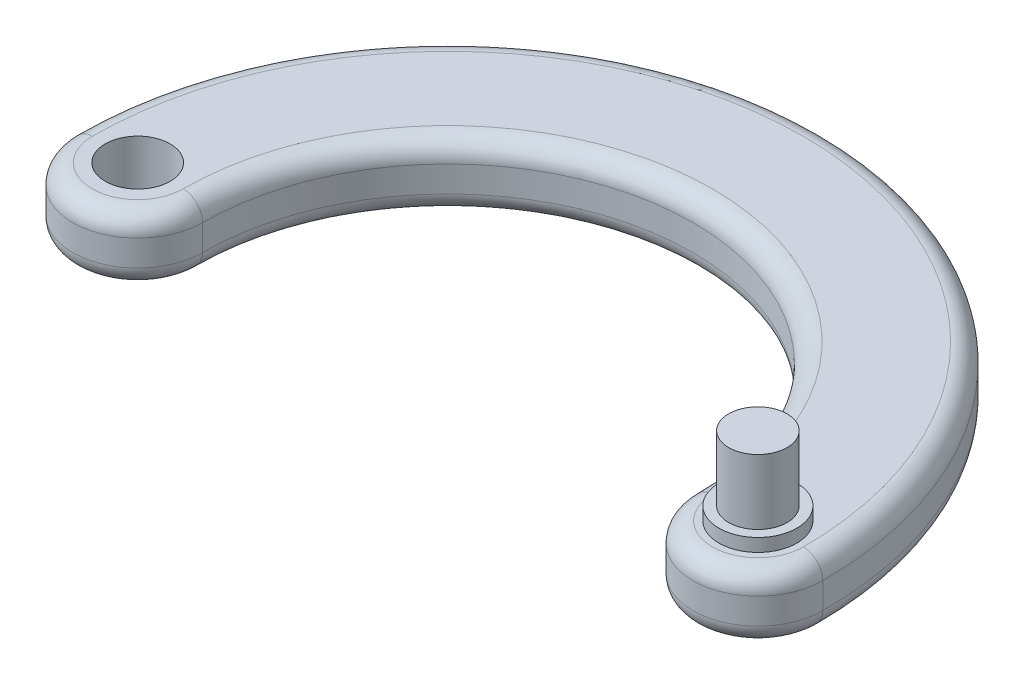
from build123d import *

# Parameters (mm, degrees)
SKETCH1_R                = 5
BOSS_EXTRUDE1_DEPTH      = 10
SKETCH2_R                = 4.5
BOSS_EXTRUDE2_DEPTH      = 12
BOSS_EXTRUDE2_DEPTH_BACK = 10
SKETCH3_R                = 5
BOSS_EXTRUDE3_DEPTH      = 10
SKETCH4_R                = 6
BOSS_EXTRUDE4_DEPTH      = 2
FILLET1_R                = 3


with BuildPart() as part:
    # Sketch1 → Boss-Extrude1 (new body)
    with BuildSketch(Plane(origin=(0, 0, 0), x_dir=(1, 0, 0), z_dir=(0, 1, 0))):
        with BuildLine():
            ThreePointArc((-10, 0), (0, -10), (10, 0))
            ThreePointArc((10, 0), (-47.75, 57.75), (-105.5, 0))
            ThreePointArc((-105.5, 0), (-95.5, -10), (-85.5, 0))
            ThreePointArc((-85.5, 0), (-47.75, 37.75), (-10, 0))
        make_face()
        with Locations((-95.5, 0)):
            Circle(SKETCH1_R, mode=Mode.SUBTRACT)
        Circle(SKETCH1_R, mode=Mode.SUBTRACT)
    extrude(amount=BOSS_EXTRUDE1_DEPTH)



with BuildPart() as body_2:
    # Sketch2 → Boss-Extrude2 (new body, two sides)
    with BuildSketch(Plane(origin=(0, 10, 0), x_dir=(1, 0, 0), z_dir=(0, 1, 0))) as boss_extrude2_sk:
        Circle(SKETCH2_R)
    extrude(amount=BOSS_EXTRUDE2_DEPTH)
    extrude(boss_extrude2_sk.sketch, amount=-BOSS_EXTRUDE2_DEPTH_BACK)


with BuildPart() as part_1:
    add(part.part)

    add(body_2.part)  # Boss-Extrude3 merges body 2
    # Sketch3 → Boss-Extrude3 (add)
    with BuildSketch(Plane(origin=(0, 10, 0), x_dir=(1, 0, 0), z_dir=(0, 1, 0))):
        Circle(SKETCH3_R)
    extrude(amount=-BOSS_EXTRUDE3_DEPTH)

    # Sketch4 → Boss-Extrude4 (add)
    with BuildSketch(Plane(origin=(0, 10, 0), x_dir=(1, 0, 0), z_dir=(0, 1, 0))):
        Circle(SKETCH4_R)
    extrude(amount=BOSS_EXTRUDE4_DEPTH)

    # Fillet1
    fillet1_edges = [part_1.edges().sort_by_distance(p)[0] for p in [
        (-47.75, 10, -37.75),
        (0, 10, 10),
        (-47.75, 10, -57.75),
        (0, 0, 10),
        (-47.75, 0, -37.75),
        (-95.5, 0, 10),
        (-47.75, 0, -57.75),
        (-95.5, 10, 10),
    ]]
    fillet(fillet1_edges, radius=FILLET1_R)


solid = part_1.part
